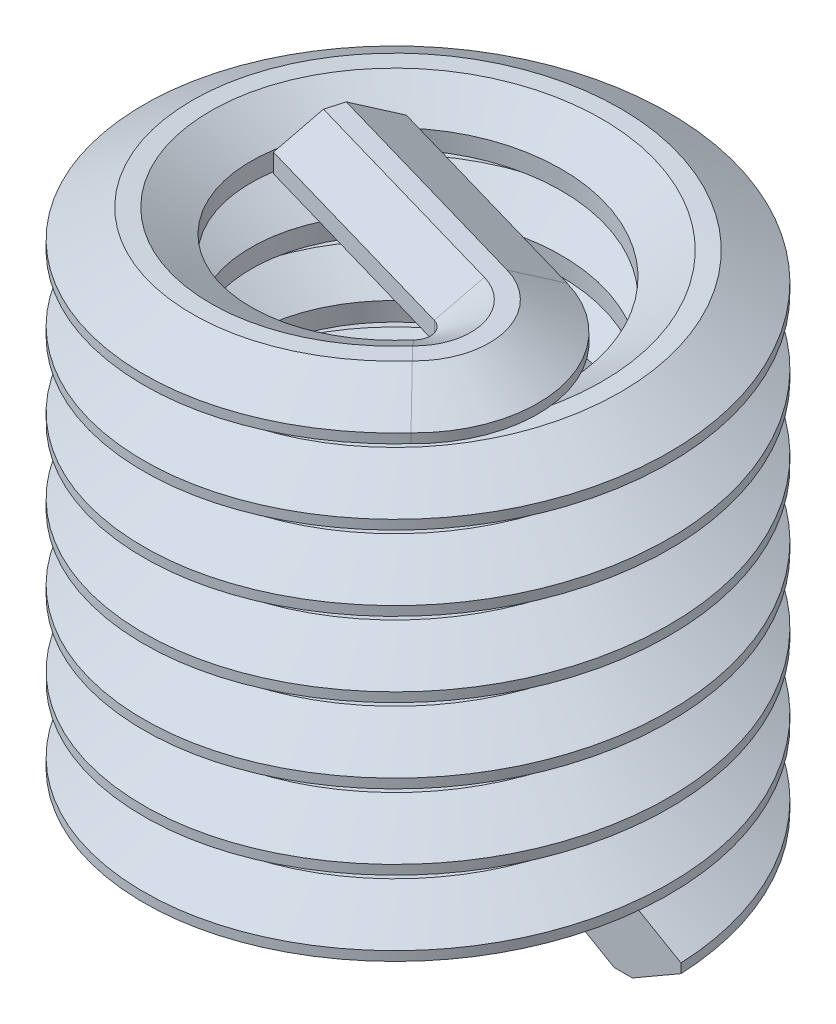
from build123d import *

# Parameters (mm, degrees)
SWEEP1_PITCH       = 0.79375
SWEEP1_HEIGHT      = 5.45465
SWEEP1_RADIUS      = 2.0828
SWEEP1_START_ANGLE = 90
REVOLVE1_ANGLE     = 120
EXTRUDE1_DEPTH     = 2.49936


with BuildPart() as part:
    # Sweep1: sweep along a helix
    with BuildLine() as sweep1_path:
        add(Helix(SWEEP1_PITCH, SWEEP1_HEIGHT, SWEEP1_RADIUS, center=(0, 0, 0), direction=(0, 1, 0), mode=Mode.PRIVATE).rotate(Axis((0, 0, 0), (0, 1, 0)), SWEEP1_START_ANGLE))
    # Sketch1 → Sweep1 (sweep)
    with BuildSketch(Plane(origin=(0, 0, 0), x_dir=(-1, 0, 0), z_dir=(0, 0, 1))):
        Polygon((-2.794, -0.049609375), (-2.278444252, -0.347265625), (-2.0828, -0.347265625), (-1.65317021, -0.09921875), (-1.65317021, 0.09921875), (-2.0828, 0.347265625), (-2.278444252, 0.347265625), (-2.794, 0.049609375), align=None)
    sweep(path=sweep1_path.line, is_frenet=True)


with BuildPart() as body_2:
    # Sketch3 → Revolve1 (revolve)
    with BuildSketch(Plane(origin=(0, 0, 0), x_dir=(-0.693649667, 0, -0.720312529), z_dir=(0.720312529, 0, -0.693649667))):
        Polygon((-2.0828, 5.10749877), (-1.65317021, 5.355545645), (-1.65317021, 5.553983369), (-2.0828, 5.802030307), (-2.278444252, 5.802030415), (-2.794, 5.504374165), (-2.794, 5.405155307), (-2.278444252, 5.107498994), align=None)
    revolve(axis=Axis((1.027515822, 5.454764494, 1.067012002), (0, 1, 0)), revolution_arc=REVOLVE1_ANGLE)

    # Sketch4 → Extrude1 (add)
    with BuildSketch(Plane(origin=(1.232666616, 0, 0.355331599), x_dir=(-0.276984115, 0, 0.960874498), z_dir=(-0.960874498, 0, -0.276984115))):
        with BuildLine():
            Line((-0.05646707, 5.107498994), (0.139177182, 5.107498769))
            Line((0.139177182, 5.107498769), (0.568806972, 5.355545644))
            Line((0.568806972, 5.355545644), (0.568806972, 5.553983369))
            Line((0.568806972, 5.553983369), (0.139177182, 5.802030307))
            add(Edge.make_bspline(
                [(0.139177182, 5.802030307), (-0.05646707, 5.802030415)],
                knots=[0, 0, 1, 1], degree=1))
            Line((-0.05646707, 5.802030415), (-0.572022818, 5.504374165))
            Line((-0.572022818, 5.504374165), (-0.572022818, 5.405155307))
            Line((-0.572022818, 5.405155307), (-0.05646707, 5.107498994))
        make_face()
    extrude(amount=EXTRUDE1_DEPTH)


solid = Compound([part.part, body_2.part])
